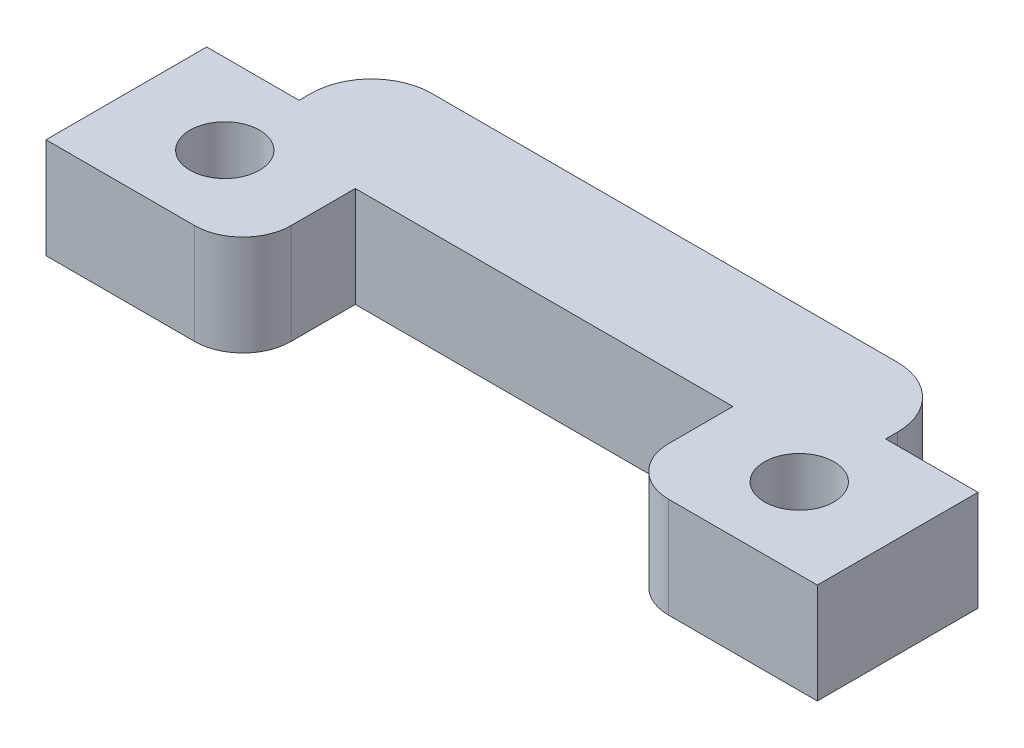
from build123d import *

# Parameters (mm, degrees)
BOSS_EXTRUDE1_DEPTH  = 3.175
M2_CLEARANCE_HOLE1_D = 2.2
SKETCH4_W            = 2.921
SKETCH4_H            = 2.286
CUT_EXTRUDE1_DEPTH   = 4.175
FILLET1_R            = 1.905


with BuildPart() as part:
    # Sketch1 → Boss-Extrude1 (new body)
    with BuildSketch(Plane(origin=(0, 0, 0), x_dir=(1, 0, 0), z_dir=(0, 1, 0))):
        with BuildLine():
            Line((0, -0.127190553), (4.699, -0.127190553))
            ThreePointArc((4.699, -0.127190553), (5.776630735, 0.319178713), (6.223, 1.396809447))
            Line((6.223, 1.396809447), (6.223, 3.428809447))
            Line((6.223, 3.428809447), (18.161, 3.428809447))
            Line((18.161, 3.428809447), (18.161, 1.396809447))
            ThreePointArc((18.161, 1.396809447), (18.607369265, 0.319178713), (19.685, -0.127190553))
            Line((19.685, -0.127190553), (24.384, -0.127190553))
            Line((24.384, -0.127190553), (24.384, 7.238809447))
            Line((24.384, 7.238809447), (0, 7.238809447))
            Line((0, 7.238809447), (0, -0.127190553))
        make_face()
    extrude(amount=BOSS_EXTRUDE1_DEPTH)

    # M2 Clearance Hole1 (through all)
    with Locations(Plane(origin=(0, 0, 0), x_dir=(-1, 0, 0), z_dir=(0, -1, 0))):
        with Locations((-3.1115, 2.412809447), (-21.2725, 2.412809447)):
            Hole(M2_CLEARANCE_HOLE1_D / 2)

    # Sketch4 → Cut-Extrude1 (cut, through all)
    with BuildSketch(Plane.XZ):
        with Locations((22.9235, -6.095809447)):
            Rectangle(SKETCH4_W, SKETCH4_H)
        with Locations((1.4605, -6.095809447)):
            Rectangle(SKETCH4_W, SKETCH4_H)
    extrude(amount=-CUT_EXTRUDE1_DEPTH, mode=Mode.SUBTRACT)

    # Fillet1
    fillet1_edges = [part.edges().sort_by_distance(p)[0] for p in [
        (21.463, 1.5875, -7.238809447),
        (2.921, 1.5875, -7.238809447),
    ]]
    fillet(fillet1_edges, radius=FILLET1_R)


solid = part.part
